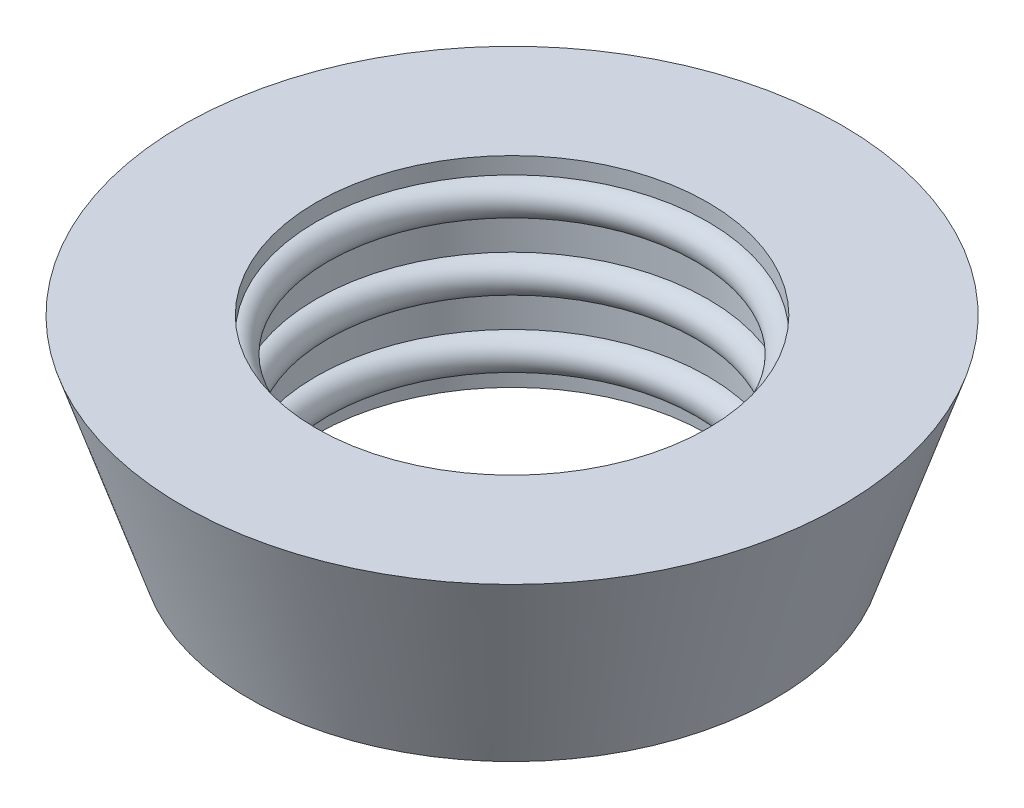
from build123d import *


with BuildPart() as part:
    # Sketch1 → Revolve1 (revolve)
    with BuildSketch(Plane.XY):
        with BuildLine():
            Line((5.85, 0), (7.85, 0))
            Line((7.85, 0), (9.85, 6))
            Line((9.85, 6), (5.85, 6))
            Line((5.85, 6), (5.85, 5.5))
            ThreePointArc((5.85, 5.5), (5.35, 5), (5.85, 4.5))
            Line((5.85, 4.5), (5.85, 3.5))
            ThreePointArc((5.85, 3.5), (5.35, 3), (5.85, 2.5))
            Line((5.85, 2.5), (5.85, 1.5))
            ThreePointArc((5.85, 1.5), (5.35, 1), (5.85, 0.5))
            Line((5.85, 0.5), (5.85, 0))
        make_face()
    revolve(axis=Axis((0, 0, 0), (0, 1, 0)))


solid = part.part
